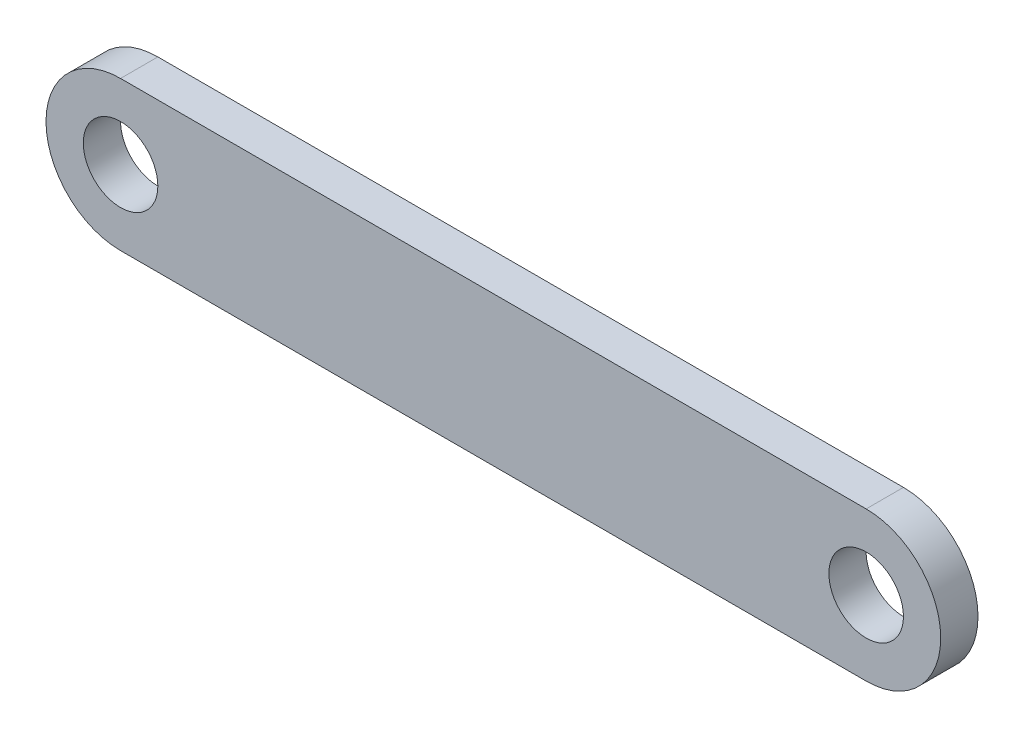
from build123d import *

# Parameters (mm, degrees)
SKETCH1_R           = 5
BOSS_EXTRUDE1_DEPTH = 5


with BuildPart() as part:
    # Sketch1 → Boss-Extrude1 (new body)
    with BuildSketch(Plane.XY):
        with BuildLine():
            Line((0, 10), (100, 10))
            ThreePointArc((100, 10), (110, 0), (100, -10))
            Line((100, -10), (0, -10))
            ThreePointArc((0, -10), (-10, 0), (0, 10))
        make_face()
        Circle(SKETCH1_R, mode=Mode.SUBTRACT)
        with Locations((100, 0)):
            Circle(SKETCH1_R, mode=Mode.SUBTRACT)
    extrude(amount=BOSS_EXTRUDE1_DEPTH)


solid = part.part
